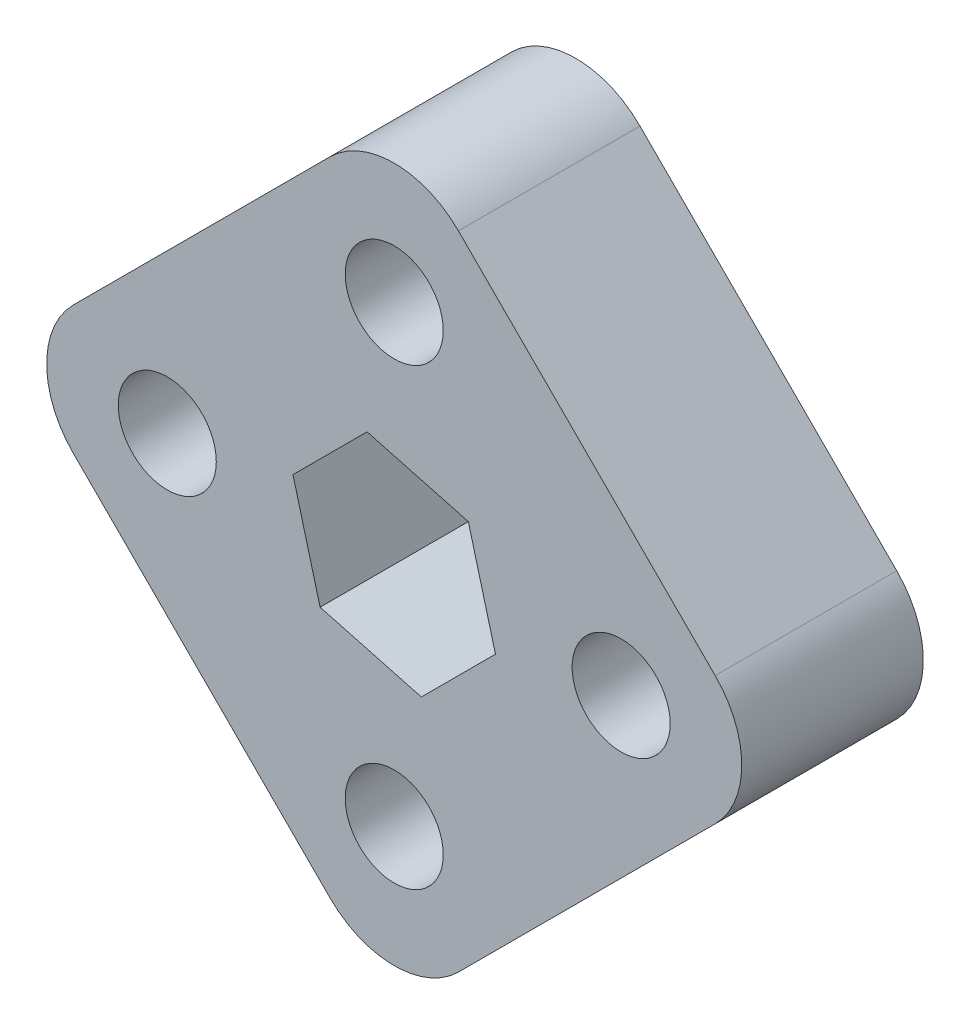
from build123d import *

# Parameters (mm, degrees)
SKETCH2_R           = 3.429
BOSS_EXTRUDE1_DEPTH = 12.7


with BuildPart() as part:
    # Sketch2 → Boss-Extrude1 (new body)
    with BuildSketch(Plane.XY):
        with BuildLine():
            Line((-4.490128061, 22.450640303), (-22.450640303, 4.490128061))
            ThreePointArc((-22.450640303, 4.490128061), (-24.310512242, 0), (-22.450640303, -4.490128061))
            Line((-22.450640303, -4.490128061), (-4.490128061, -22.450640303))
            ThreePointArc((-4.490128061, -22.450640303), (0, -24.310512242), (4.490128061, -22.450640303))
            Line((4.490128061, -22.450640303), (22.450640303, -4.490128061))
            ThreePointArc((22.450640303, -4.490128061), (24.310512242, 0), (22.450640303, 4.490128061))
            Line((22.450640303, 4.490128061), (4.490128061, 22.450640303))
            ThreePointArc((4.490128061, 22.450640303), (0, 24.310512242), (-4.490128061, 22.450640303))
        make_face()
        with Locations((0, 15.875)):
            Circle(SKETCH2_R, mode=Mode.SUBTRACT)
        with Locations((15.875, 0)):
            Circle(SKETCH2_R, mode=Mode.SUBTRACT)
        with Locations((0, -15.875)):
            Circle(SKETCH2_R, mode=Mode.SUBTRACT)
        with Locations((-15.875, 0)):
            Circle(SKETCH2_R, mode=Mode.SUBTRACT)
        Polygon((5.184753289, 5.184753289), (-1.897751416, 7.082504705), (-7.082504705, 1.897751416), (-5.184753289, -5.184753289), (1.897751416, -7.082504705), (7.082504705, -1.897751416), align=None, mode=Mode.SUBTRACT)
    extrude(amount=BOSS_EXTRUDE1_DEPTH)


solid = part.part
